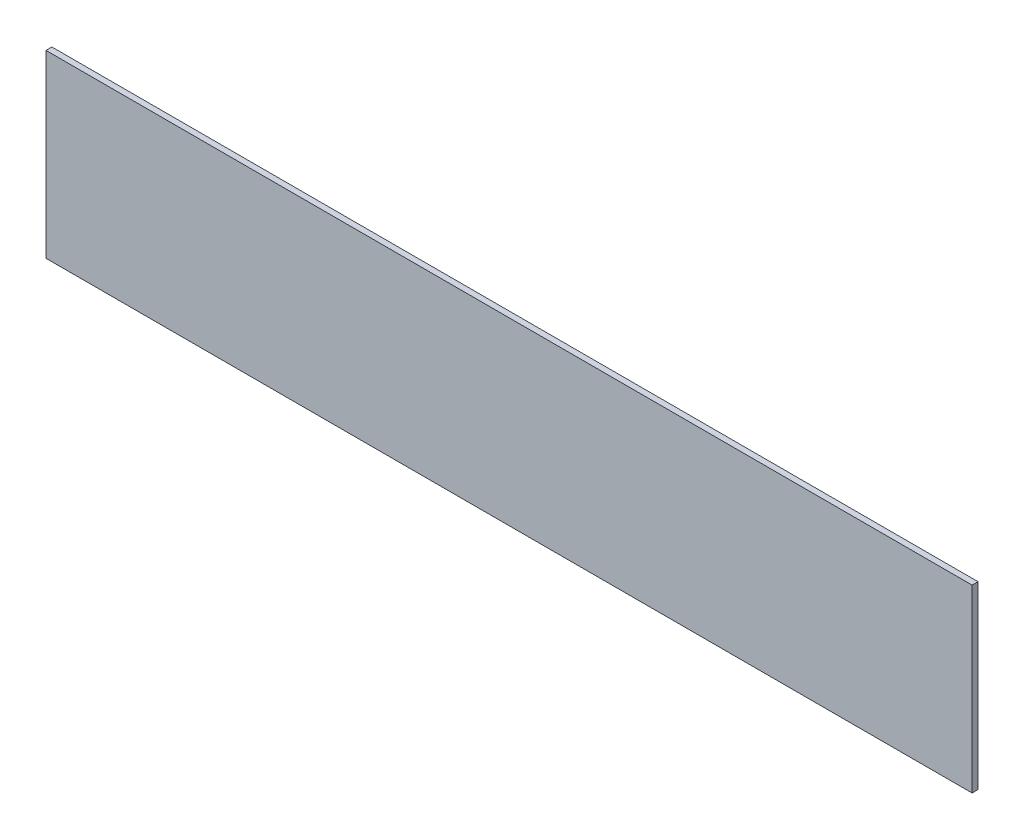
from build123d import *

# Parameters (mm, degrees)
SKETCH1_W           = 457.2
SKETCH1_H           = 88.9
BOSS_EXTRUDE1_DEPTH = 2.921


with BuildPart() as part:
    # Sketch1 → Boss-Extrude1 (new body)
    with BuildSketch(Plane.XY):
        with Locations((0, -527.543937925)):
            Rectangle(SKETCH1_W, SKETCH1_H)
    extrude(amount=BOSS_EXTRUDE1_DEPTH)


solid = part.part
